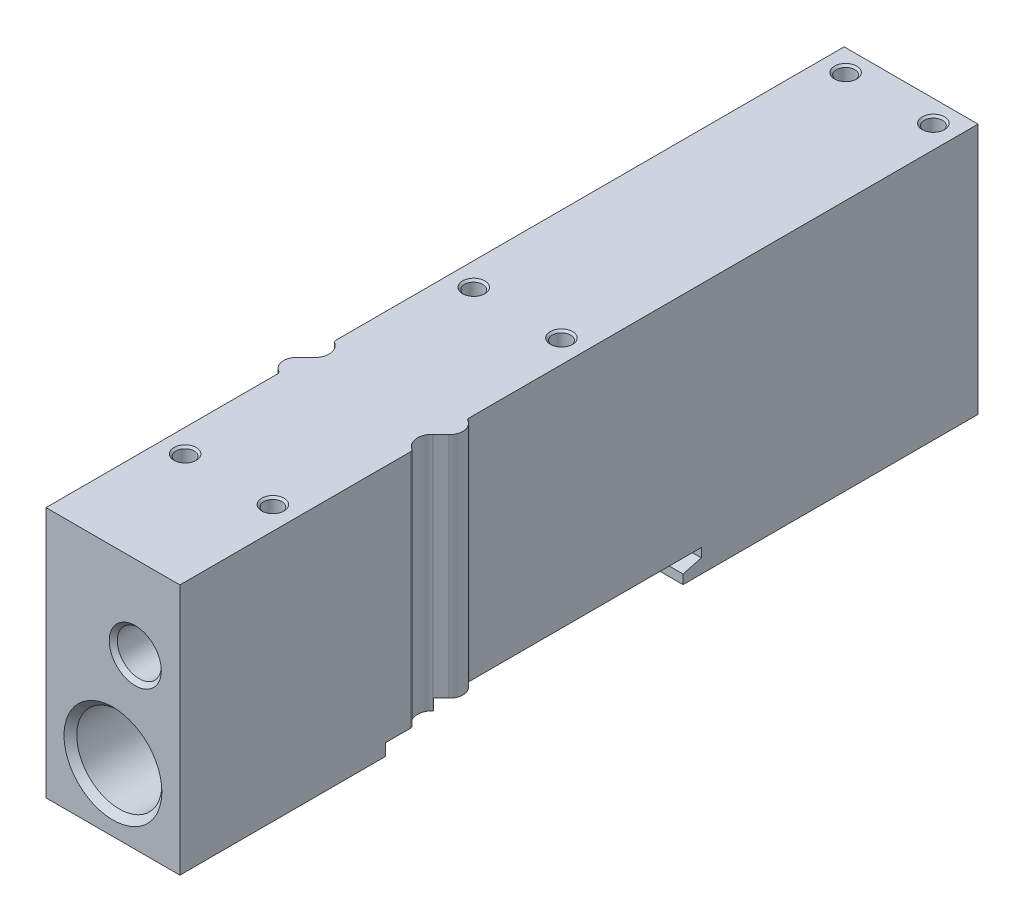
from build123d import *

# Parameters (mm, degrees)
BOSS_EXTRUDE1_DEPTH     = 33.8
CUT_EXTRUDE1_DEPTH      = 23
CUT_EXTRUDE1_DEPTH_BACK = 23


with BuildPart() as part:
    # Sketch1 → Boss-Extrude1 (new body)
    with BuildSketch(Plane(origin=(0, 1.3, 0), x_dir=(1, 0, 0), z_dir=(0, 1, 0))):
        with BuildLine():
            Line((0, -22.541858429), (0, -53.65))
            Line((0, -53.65), (18, -53.65))
            Line((18, -53.65), (18, -22.654162541))
            ThreePointArc((18, -22.654162541), (17.938748215, -22.414370958), (17.769999986, -22.233330024))
            ThreePointArc((17.769999986, -22.233330024), (16.858228534, -20.731235829), (17.483912522, -19.089245057))
            Line((17.483912522, -19.089245057), (18.57947873, -18.064679449))
            ThreePointArc((18.57947873, -18.064679449), (19.138283161, -16.544955286), (18.250000071, -15.191154314))
            ThreePointArc((18.250000071, -15.191154314), (18.066987319, -15.008141607), (18, -14.758141571))
            Line((18, -14.758141571), (18, 53.65))
            Line((18, 53.65), (0, 53.65))
            Line((0, 53.65), (0, -14.645837459))
            ThreePointArc((0, -14.645837459), (0.061251781, -14.885629035), (0.23, -15.066669967))
            ThreePointArc((0.23, -15.066669967), (1.141771466, -16.568764162), (0.516087478, -18.210754943))
            Line((0.516087478, -18.210754943), (-0.57947873, -19.235320551))
            ThreePointArc((-0.57947873, -19.235320551), (-1.138283159, -20.755044733), (-0.250000037, -22.108845706))
            ThreePointArc((-0.250000037, -22.108845706), (-0.066987309, -22.29185841), (0, -22.541858429))
        make_face()
    extrude(amount=BOSS_EXTRUDE1_DEPTH)

    # Sketch2 → Cut-Extrude1 (cut, two sides)
    with BuildSketch(Plane(origin=(0, 0, 0), x_dir=(0, 0, -1), z_dir=(1, 0, 0))) as cut_extrude1_sk:
        Polygon((-26, 2.9), (-26, -8.174443219), (14, -7.963716906), (14, 2.543524479), (16.45, 3.2), (16.45, 4.4), (-19.05, 4.4), (-19.05, 2.9), align=None)
    extrude(amount=CUT_EXTRUDE1_DEPTH, mode=Mode.SUBTRACT)
    extrude(cut_extrude1_sk.sketch, amount=-CUT_EXTRUDE1_DEPTH_BACK, mode=Mode.SUBTRACT)

    # Sketch3 → Cut-Revolve1 (revolve, cut)
    with BuildSketch(Plane(origin=(9, 0, 0), x_dir=(0, 0, -1), z_dir=(1, 0, 0))):
        Polygon((-53.65, 9.8), (-53.65, 16.3785), (-52.794, 15.5225), (-40.65, 15.5225), (-40.65, 9.8), align=None)
    revolve(axis=Axis((9, 9.8, 40.65), (0, 0, 1)), mode=Mode.SUBTRACT)

    # Sketch4 → Cut-Revolve2 (revolve, cut)
    with BuildSketch(Plane(origin=(12, 0, 0), x_dir=(0, 0, -1), z_dir=(1, 0, 0))):
        Polygon((-53.65, 23.86), (-53.65, 27.36), (-53.1085, 26.8185), (-46.65, 26.8185), (-46.65, 23.86), align=None)
    revolve(axis=Axis((12, 23.86, 46.65), (0, 0, 1)), mode=Mode.SUBTRACT)

    # Sketch5 → Cut-Revolve3 (revolve, cut)
    with BuildSketch(Plane(origin=(3.1, 0, 0), x_dir=(0, 0, -1), z_dir=(1, 0, 0))):
        Polygon((-38.05, 35.1), (-36.55, 35.1), (-36.8205, 34.8295), (-36.8205, 30.1), (-38.05, 30.1), align=None)
    revolve(axis=Axis((3.1, 30.1, 38.05), (0, 1, 0)), mode=Mode.SUBTRACT)

    # Sketch6 → Cut-Revolve4 (revolve, cut)
    with BuildSketch(Plane(origin=(3.1, 0, 0), x_dir=(0, 0, -1), z_dir=(1, 0, 0))):
        Polygon((0.75, 35.1), (2.25, 35.1), (1.9795, 34.8295), (1.9795, 30.1), (0.75, 30.1), align=None)
    revolve(axis=Axis((3.1, 30.1, -0.75), (0, 1, 0)), mode=Mode.SUBTRACT)

    # Sketch7 → Cut-Revolve5 (revolve, cut)
    with BuildSketch(Plane(origin=(3.1, 0, 0), x_dir=(0, 0, -1), z_dir=(1, 0, 0))):
        Polygon((50.75, 35.1), (52.25, 35.1), (51.9795, 34.8295), (51.9795, 30.1), (50.75, 30.1), align=None)
    revolve(axis=Axis((3.1, 30.1, -50.75), (0, 1, 0)), mode=Mode.SUBTRACT)

    # Sketch8 → Cut-Revolve6 (revolve, cut)
    with BuildSketch(Plane(origin=(14.9, 0, 0), x_dir=(0, 0, -1), z_dir=(1, 0, 0))):
        Polygon((-38.05, 35.1), (-36.55, 35.1), (-36.8205, 34.8295), (-36.8205, 30.1), (-38.05, 30.1), align=None)
    revolve(axis=Axis((14.9, 30.1, 38.05), (0, 1, 0)), mode=Mode.SUBTRACT)

    # Sketch9 → Cut-Revolve7 (revolve, cut)
    with BuildSketch(Plane(origin=(14.9, 0, 0), x_dir=(0, 0, -1), z_dir=(1, 0, 0))):
        Polygon((0.75, 35.1), (2.25, 35.1), (1.9795, 34.8295), (1.9795, 30.1), (0.75, 30.1), align=None)
    revolve(axis=Axis((14.9, 30.1, -0.75), (0, 1, 0)), mode=Mode.SUBTRACT)

    # Sketch10 → Cut-Revolve8 (revolve, cut)
    with BuildSketch(Plane(origin=(14.9, 0, 0), x_dir=(0, 0, -1), z_dir=(1, 0, 0))):
        Polygon((50.75, 35.1), (52.25, 35.1), (51.9795, 34.8295), (51.9795, 30.1), (50.75, 30.1), align=None)
    revolve(axis=Axis((14.9, 30.1, -50.75), (0, 1, 0)), mode=Mode.SUBTRACT)

    # Sketch11 → Cut-Revolve9 (revolve, cut)
    with BuildSketch(Plane(origin=(0, 13, 0), x_dir=(1, 0, 0), z_dir=(0, 1, 0))):
        Polygon((12.75, 53.65), (14.665, 53.65), (14.165, 53.15), (14.165, 44.65), (12.75, 43.833049369), align=None)
    revolve(axis=Axis((12.75, 13, -43.833049369), (0, 0, -1)), mode=Mode.SUBTRACT)

    # Sketch12 → Cut-Revolve10 (revolve, cut)
    with BuildSketch(Plane(origin=(0, 13, 0), x_dir=(1, 0, 0), z_dir=(0, 1, 0))):
        Polygon((5.25, 53.65), (7.165, 53.65), (6.665, 53.15), (6.665, 44.65), (5.25, 43.833049369), align=None)
    revolve(axis=Axis((5.25, 13, -43.833049369), (0, 0, -1)), mode=Mode.SUBTRACT)


solid = part.part
